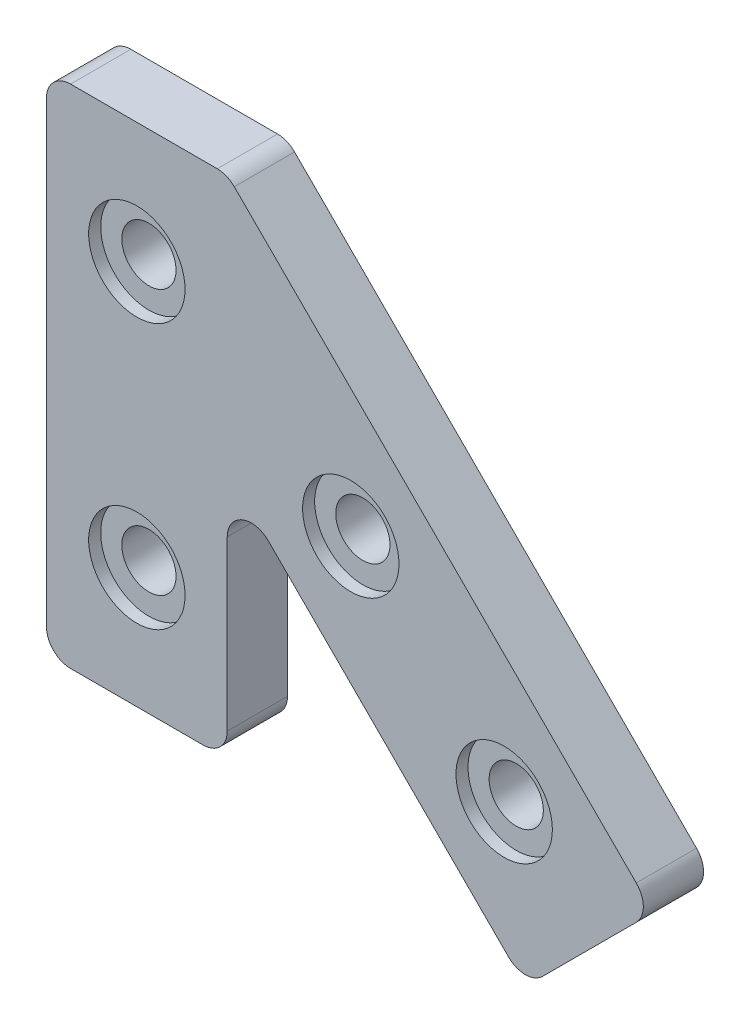
from build123d import *

# Parameters (mm, degrees)
BOSS_EXTRUDE1_DEPTH = 5
SKETCH2_R           = 4
CUT_EXTRUDE1_DEPTH  = 1
SKETCH3_R           = 2.25
CUT_EXTRUDE2_DEPTH  = 16
FILLET1_R           = 2


with BuildPart() as part:
    # Sketch1 → Boss-Extrude1 (new body)
    with BuildSketch(Plane.XY):
        Polygon((0, 0), (0, 42), (15, 42), (50.355339059, 6.644660941), (39.748737342, -3.961940777), (15, 20.786796564), (15, 0), align=None)
    extrude(amount=BOSS_EXTRUDE1_DEPTH)

    # Sketch2 → Cut-Extrude1 (cut)
    with BuildSketch(Plane.XY.offset(5)):
        with Locations((7.5, 10)):
            Circle(SKETCH2_R)
        with Locations((7.5, 32)):
            Circle(SKETCH2_R)
        with Locations((37.980970389, 8.412427894)):
            Circle(SKETCH2_R)
        with Locations((25.253048327, 21.140349955)):
            Circle(SKETCH2_R)
    extrude(amount=-CUT_EXTRUDE1_DEPTH, mode=Mode.SUBTRACT)

    # Sketch3 → Cut-Extrude2 (cut)
    with BuildSketch(Plane.XY.offset(4)):
        with Locations((7.5, 32)):
            Circle(SKETCH3_R)
        with Locations((7.5, 10)):
            Circle(SKETCH3_R)
        with Locations((25.253048327, 21.140349955)):
            Circle(SKETCH3_R)
        with Locations((37.980970389, 8.412427894)):
            Circle(SKETCH3_R)
    extrude(amount=-CUT_EXTRUDE2_DEPTH, mode=Mode.SUBTRACT)

    # Fillet1
    fillet1_edges = [part.edges().sort_by_distance(p)[0] for p in [
        (0, 0, 2.5),
        (0, 42, 2.5),
        (15, 42, 2.5),
        (50.355339059, 6.644660941, 2.5),
        (39.748737342, -3.961940777, 2.5),
        (15, 20.786796564, 2.5),
        (15, 0, 2.5),
    ]]
    fillet(fillet1_edges, radius=FILLET1_R)


solid = part.part
